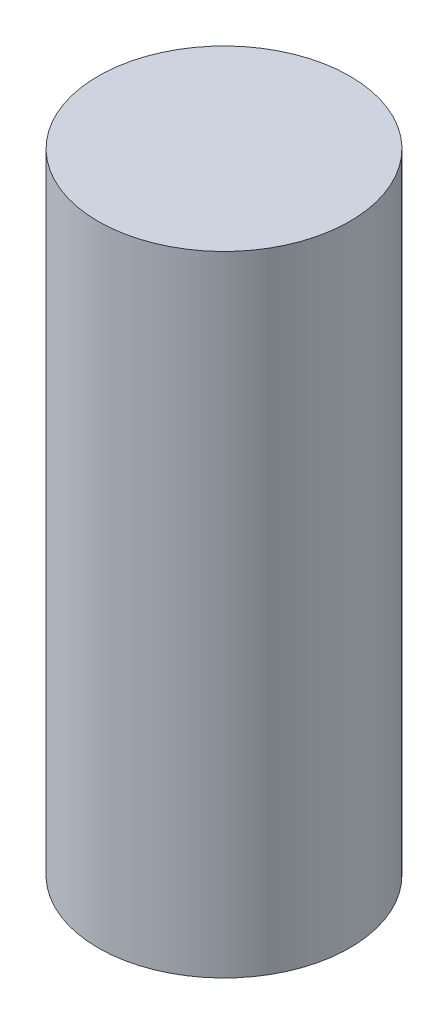
from build123d import *

# Parameters (mm, degrees)
SKETCH_1_R      = 13
EXTRUDE_1_DEPTH = 65


with BuildPart() as part:
    # 스케치1 → 보스-돌출1 (new body)
    with BuildSketch(Plane(origin=(0, 0, 0), x_dir=(1, 0, 0), z_dir=(0, 1, 0))):
        Circle(SKETCH_1_R)
    extrude(amount=EXTRUDE_1_DEPTH)


solid = part.part
